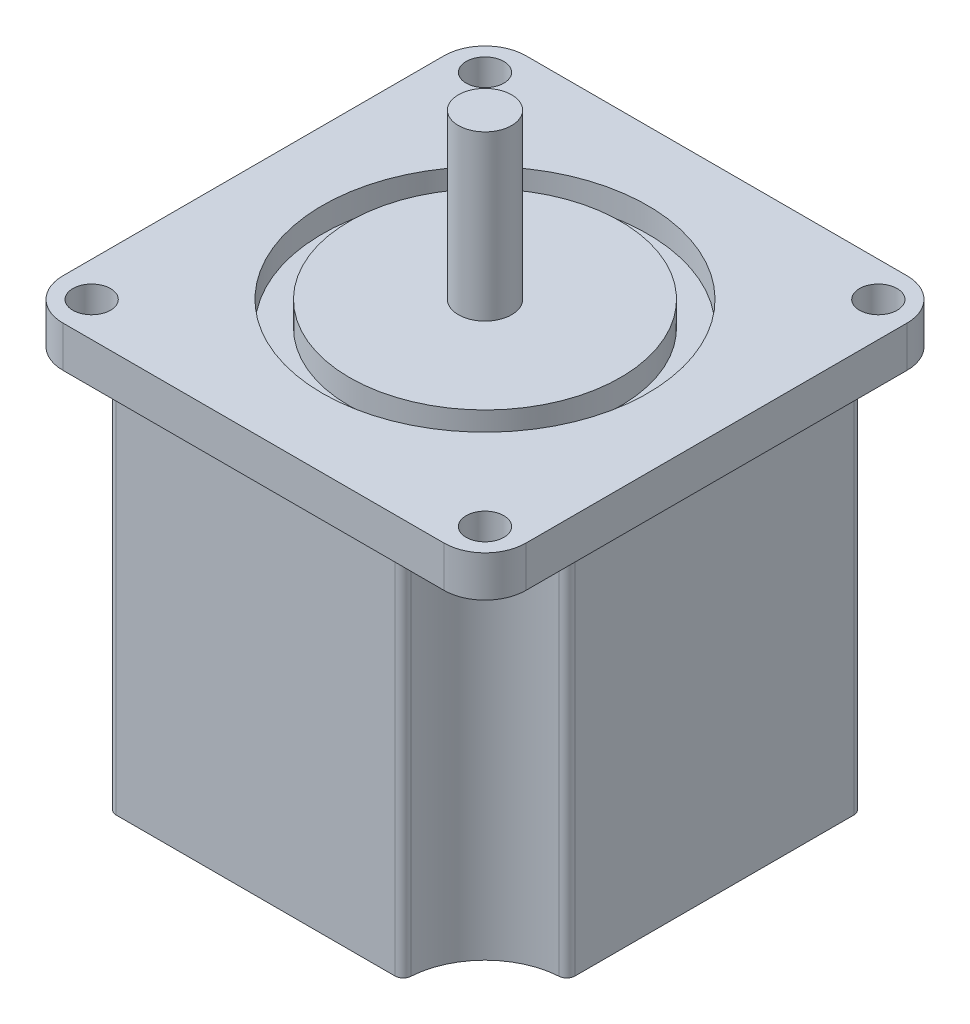
from build123d import *

# Parameters (mm, degrees)
SKETCH1_W                                = 56
SKETCH1_H                                = 56
BOSS_EXTRUDE1_DEPTH                      = 44
SKETCH2_W                                = 56.5
SKETCH2_H                                = 56.5
SKETCH2_R                                = 2.3
BOSS_EXTRUDE2_DEPTH                      = 5
SKETCH3_R                                = 19.851731711
SKETCH3_R_2                              = 16.528882373
CUT_EXTRUDE1_DEPTH                       = 3
SKETCH4_R                                = 3.25
BOSS_EXTRUDE3_DEPTH                      = 20
CUT_EXTRUDE2_DEPTH                       = 44
MIRROR1_AT_THE_SECOND_PLANE_COPY_1_DEPTH = 44
FILLET3_R                                = 1
FILLET2_R                                = 5


with BuildPart() as part:
    # Sketch1 → Boss-Extrude1 (new body)
    with BuildSketch(Plane(origin=(0, 0, 0), x_dir=(1, 0, 0), z_dir=(0, 1, 0))):
        Rectangle(SKETCH1_W, SKETCH1_H)
    extrude(amount=BOSS_EXTRUDE1_DEPTH)

    # Sketch2 → Boss-Extrude2 (add)
    with BuildSketch(Plane(origin=(0, 44, 0), x_dir=(1, 0, 0), z_dir=(0, 1, 0))):
        Rectangle(SKETCH2_W, SKETCH2_H)
        with Locations((-24, 24)):
            Circle(SKETCH2_R, mode=Mode.SUBTRACT)
        with Locations((24, 24)):
            Circle(SKETCH2_R, mode=Mode.SUBTRACT)
        with Locations((-24, -24)):
            Circle(SKETCH2_R, mode=Mode.SUBTRACT)
        with Locations((24, -24)):
            Circle(SKETCH2_R, mode=Mode.SUBTRACT)
    extrude(amount=BOSS_EXTRUDE2_DEPTH)

    # Sketch3 → Cut-Extrude1 (cut)
    with BuildSketch(Plane(origin=(0, 49, 0), x_dir=(1, 0, 0), z_dir=(0, 1, 0))):
        Circle(SKETCH3_R)
        Circle(SKETCH3_R_2, mode=Mode.SUBTRACT)
    extrude(amount=-CUT_EXTRUDE1_DEPTH, mode=Mode.SUBTRACT)

    # Sketch4 → Boss-Extrude3 (add)
    with BuildSketch(Plane(origin=(0, 49, 0), x_dir=(1, 0, 0), z_dir=(0, 1, 0))):
        Circle(SKETCH4_R)
    extrude(amount=BOSS_EXTRUDE3_DEPTH)

    # Sketch5 → Cut-Extrude2 (cut)
    with BuildSketch(Plane.XZ):
        with BuildLine():
            Line((-28, 18), (-28, 28))
            Line((-28, 28), (-18, 28))
            ThreePointArc((-18, 28), (-20.83143897, 20.83143897), (-28, 18))
        make_face()
    cut_extrude2 = extrude(amount=-CUT_EXTRUDE2_DEPTH, mode=Mode.SUBTRACT)

    # Mirror1: Cut-Extrude2 across plane
    add(cut_extrude2.mirror(Plane(origin=(0, 0, 0), x_dir=(0, 0, 1), z_dir=(1, 0, 0))), mode=Mode.SUBTRACT)

    # Mirror1 at the second plane: Cut-Extrude2 across plane
    add(cut_extrude2.mirror(Plane.XY), mode=Mode.SUBTRACT)

    # Mirror1 at the second plane copy 1 sketc → Mirror1 at the second plane copy 1 (cut)
    with BuildSketch(Plane(origin=(0, 0, 0), x_dir=(-1, 0, 0), z_dir=(0, -1, 0))):
        with BuildLine():
            Line((-28, 18), (-28, 28))
            Line((-28, 28), (-18, 28))
            ThreePointArc((-18, 28), (-20.83143897, 20.83143897), (-28, 18))
        make_face()
    extrude(amount=-MIRROR1_AT_THE_SECOND_PLANE_COPY_1_DEPTH, mode=Mode.SUBTRACT)

    # Fillet3
    fillet3_edges = [part.edges().sort_by_distance(p)[0] for p in [
        (-18, 22, 28),
        (-28, 22, 18),
        (-28, 22, -18),
        (-18, 22, -28),
        (28, 22, 18),
        (18, 22, 28),
        (18, 22, -28),
        (28, 22, -18),
    ]]
    fillet(fillet3_edges, radius=FILLET3_R)

    # Fillet2
    fillet2_edges = [part.edges().sort_by_distance(p)[0] for p in [
        (28.25, 46.5, 28.25),
        (28.25, 46.5, -28.25),
        (-28.25, 46.5, -28.25),
        (-28.25, 46.5, 28.25),
    ]]
    fillet(fillet2_edges, radius=FILLET2_R)


solid = part.part
